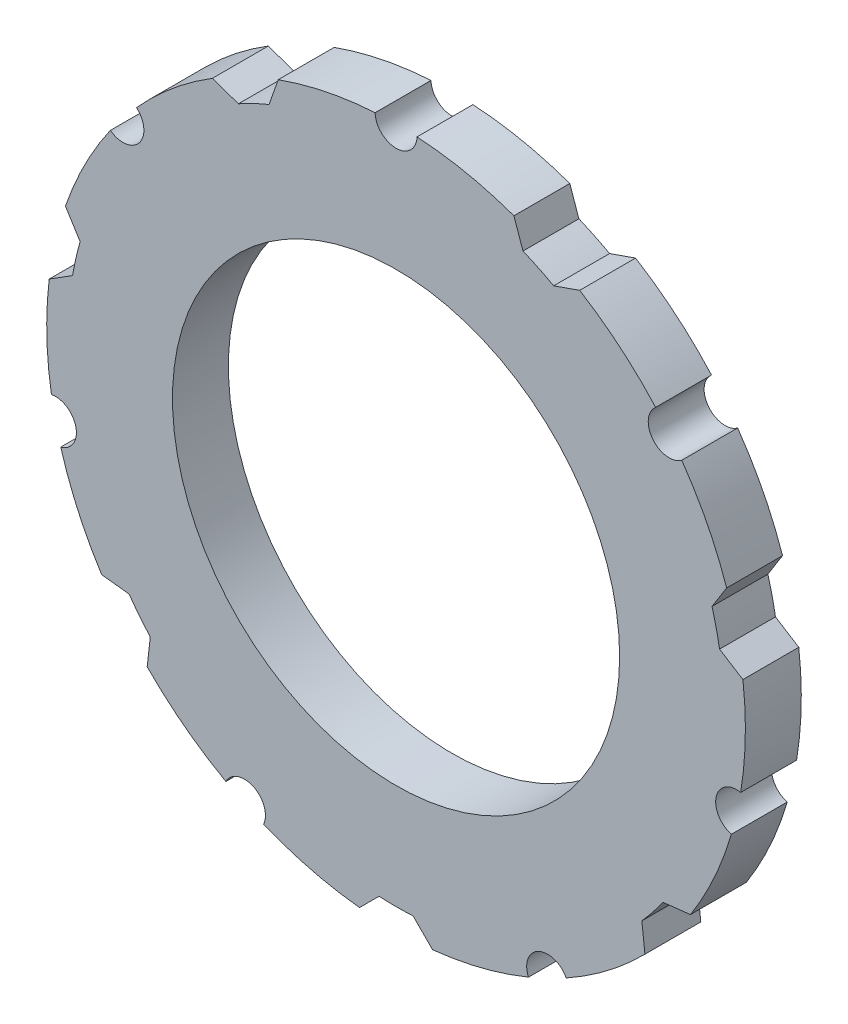
from build123d import *

# Parameters (mm, degrees)
SKETCH1_R           = 16
BOSS_EXTRUDE1_DEPTH = 4


with BuildPart() as part:
    # Sketch1 → Boss-Extrude1 (new body)
    with BuildSketch(Plane.XY):
        with BuildLine():
            Line((23.658232882, 8.080100055), (22.60887418, 6.410055249))
            ThreePointArc((22.60887418, 6.410055249), (22.910805936, 5.229241948), (23.151110514, 4.034362646))
            Line((23.151110514, 4.034362646), (24.821155321, 2.985003945))
            ThreePointArc((24.821155321, 2.985003945), (24.993754895, -0.558763162), (24.662957214, -4.091276263))
            ThreePointArc((24.662957214, -4.091276263), (22.910805936, -5.229241948), (23.995694883, -7.014743551))
            ThreePointArc((23.995694883, -7.014743551), (22.761033302, -10.340955615), (21.067943537, -13.458891304))
            Line((21.067943537, -13.458891304), (19.107985481, -13.679725541))
            ThreePointArc((19.107985481, -13.679725541), (18.373039838, -14.652010344), (17.588673036, -15.584883087))
            Line((17.588673036, -15.584883087), (17.809507272, -17.544841143))
            ThreePointArc((17.809507272, -17.544841143), (15.146492656, -19.889287575), (12.178413721, -21.833145427))
            ThreePointArc((12.178413721, -21.833145427), (10.196267869, -21.172768396), (9.476723699, -23.13421077))
            ThreePointArc((9.476723699, -23.13421077), (6.106387485, -24.242772776), (2.613063, -24.863063))
            Line((2.613063, -24.863063), (1.218393982, -23.468393982))
            ThreePointArc((1.218393982, -23.468393982), (0, -23.5), (-1.218393982, -23.468393982))
            Line((-1.218393982, -23.468393982), (-2.613063, -24.863063))
            ThreePointArc((-2.613063, -24.863063), (-6.106387485, -24.242772776), (-9.476723699, -23.13421077))
            ThreePointArc((-9.476723699, -23.13421077), (-10.196267869, -21.172768396), (-12.178413721, -21.833145427))
            ThreePointArc((-12.178413721, -21.833145427), (-15.146492656, -19.889287575), (-17.809507272, -17.544841143))
            Line((-17.809507272, -17.544841143), (-17.588673036, -15.584883087))
            ThreePointArc((-17.588673036, -15.584883087), (-18.373039838, -14.652010344), (-19.107985481, -13.679725541))
            Line((-19.107985481, -13.679725541), (-21.067943537, -13.458891304))
            ThreePointArc((-21.067943537, -13.458891304), (-22.761033302, -10.340955615), (-23.995694883, -7.014743551))
            ThreePointArc((-23.995694883, -7.014743551), (-22.910805936, -5.229241948), (-24.662957214, -4.091276263))
            ThreePointArc((-24.662957214, -4.091276263), (-24.993754895, -0.558763162), (-24.821155321, 2.985003945))
            Line((-24.821155321, 2.985003945), (-23.151110514, 4.034362646))
            ThreePointArc((-23.151110514, 4.034362646), (-22.910805936, 5.229241948), (-22.60887418, 6.410055249))
            Line((-22.60887418, 6.410055249), (-23.658232882, 8.080100055))
            ThreePointArc((-23.658232882, 8.080100055), (-22.276156802, 11.347812041), (-20.445418397, 14.386968637))
            ThreePointArc((-20.445418397, 14.386968637), (-18.373039838, 14.652010344), (-18.575790893, 16.731407374))
            ThreePointArc((-18.575790893, 16.731407374), (-16.020209918, 19.192521309), (-13.141967154, 21.267080179))
            Line((-13.141967154, 21.267080179), (-11.280289579, 20.615651021))
            ThreePointArc((-11.280289579, 20.615651021), (-10.196267869, 21.172768396), (-9.084819485, 21.672933694))
            Line((-9.084819485, 21.672933694), (-8.433390327, 23.534611269))
            ThreePointArc((-8.433390327, 23.534611269), (-5.01687988, 24.491445778), (-1.499324848, 24.955))
            ThreePointArc((-1.499324848, 24.955), (0, 23.5), (1.499324848, 24.955))
            ThreePointArc((1.499324848, 24.955), (5.01687988, 24.491445778), (8.433390327, 23.534611269))
            Line((8.433390327, 23.534611269), (9.084819485, 21.672933694))
            ThreePointArc((9.084819485, 21.672933694), (10.196267869, 21.172768396), (11.280289579, 20.615651021))
            Line((11.280289579, 20.615651021), (13.141967154, 21.267080179))
            ThreePointArc((13.141967154, 21.267080179), (16.020209918, 19.192521309), (18.575790893, 16.731407374))
            ThreePointArc((18.575790893, 16.731407374), (18.373039838, 14.652010344), (20.445418397, 14.386968637))
            ThreePointArc((20.445418397, 14.386968637), (22.276156802, 11.347812041), (23.658232882, 8.080100055))
        make_face()
        Circle(SKETCH1_R, mode=Mode.SUBTRACT)
    extrude(amount=BOSS_EXTRUDE1_DEPTH)


solid = part.part
